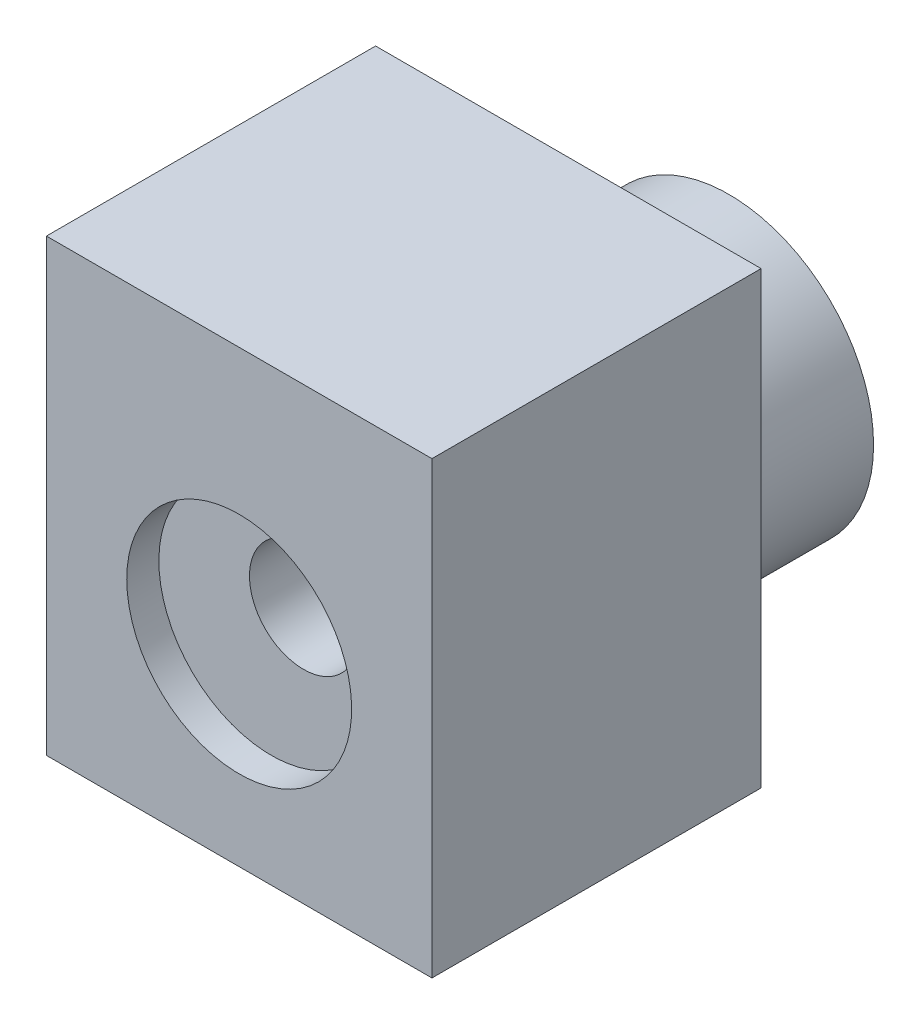
from build123d import *

# Parameters (mm, degrees)
SZKIC2_W                         = 60
SZKIC2_H                         = 51.228721397
DODANIE_WYCI_GNI_CIE1_DEPTH      = 40
DODANIE_WYCI_GNI_CIE1_DEPTH_BACK = 30
SZKIC3_R                         = 8.4
WYTNIJ_WYCI_GNI_CIE1_DEPTH       = 52.228721397
SZKIC5_R                         = 17.5
WYTNIJ_WYCI_GNI_CIE2_DEPTH       = 10
SZKIC6_W                         = 5
SZKIC6_H                         = 53
WYTNIJ_WYCI_GNI_CIE3_DEPTH       = 55
SZKIC8_R                         = 22.5
SZKIC8_R_2                       = 17.5
DODANIE_WYCI_GNI_CIE3_DEPTH      = 25


with BuildPart() as part:
    # Szkic2 → Dodanie-wyciągnięcie1 (new body, two sides)
    with BuildSketch(Plane(origin=(0, 0, 0), x_dir=(1, 0, 0), z_dir=(0, 1, 0))) as dodanie_wyci_gni_cie1_sk:
        with Locations((0, 39.614360699)):
            Rectangle(SZKIC2_W, SZKIC2_H)
    extrude(amount=DODANIE_WYCI_GNI_CIE1_DEPTH)
    extrude(dodanie_wyci_gni_cie1_sk.sketch, amount=-DODANIE_WYCI_GNI_CIE1_DEPTH_BACK)

    # Szkic3 → Wytnij-wyciągnięcie1 (cut, through all)
    with BuildSketch(Plane.XY.offset(-14)):
        Circle(SZKIC3_R)
    extrude(amount=-WYTNIJ_WYCI_GNI_CIE1_DEPTH, mode=Mode.SUBTRACT)

    # Szkic5 → Wytnij-wyciągnięcie2 (cut)
    with BuildSketch(Plane(origin=(0, 0, -65.228721397), x_dir=(-1, 0, 0), z_dir=(0, 0, -1))):
        Circle(SZKIC5_R)
    wytnij_wyci_gni_cie2 = extrude(amount=-WYTNIJ_WYCI_GNI_CIE2_DEPTH, mode=Mode.SUBTRACT)

    # Szkic6 → Wytnij-wyciągnięcie3 (cut)
    with BuildSketch(Plane.ZY.offset(30)):
        with Locations((-57.728721397, 0)):
            Rectangle(SZKIC6_W, SZKIC6_H)
    wytnij_wyci_gni_cie3 = extrude(amount=-WYTNIJ_WYCI_GNI_CIE3_DEPTH, mode=Mode.SUBTRACT)

    # Lustro1: Wytnij-wyciągnięcie2, Wytnij-wyciągnięcie3 across plane
    add(wytnij_wyci_gni_cie2.mirror(Plane(origin=(0, 0, -39.614360698), x_dir=(1, 0, 0), z_dir=(0, 0, -1))), mode=Mode.SUBTRACT)
    add(wytnij_wyci_gni_cie3.mirror(Plane(origin=(0, 0, -39.614360698), x_dir=(1, 0, 0), z_dir=(0, 0, -1))), mode=Mode.SUBTRACT)

    # Szkic8 → Dodanie-wyciągnięcie3 (add)
    with BuildSketch(Plane(origin=(0, 0, -65.228721397), x_dir=(-1, 0, 0), z_dir=(0, 0, -1))):
        Circle(SZKIC8_R)
        Circle(SZKIC8_R_2, mode=Mode.SUBTRACT)
    extrude(amount=DODANIE_WYCI_GNI_CIE3_DEPTH)


solid = part.part
